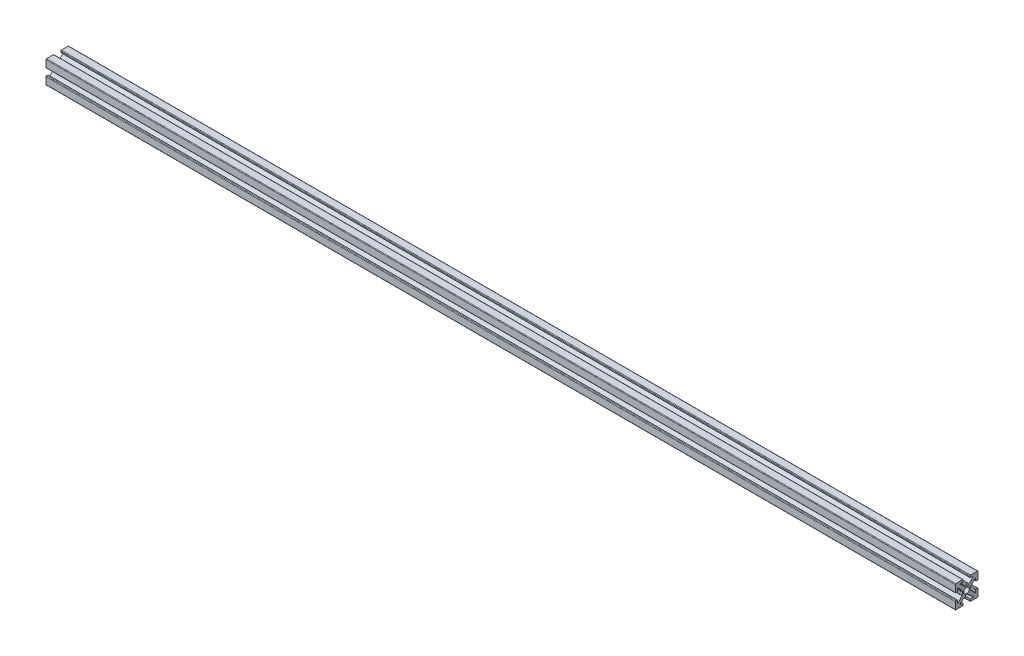
from build123d import *

# Parameters (mm, degrees)
ESTRUSIONE_ESTRUSIONE1_DEPTH = 400
FORO_FILETTATO_M3X0_5_1_D    = 2.5


with BuildPart() as part:
    # Sketch1 → Estrusione-Estrusione1 (new body)
    with BuildSketch(Plane(origin=(0, 0, 0), x_dir=(0, 0, -1), z_dir=(1, 0, 0))):
        with BuildLine():
            Line((-0.2413, 1.4986), (0.2413, 1.4986))
            ThreePointArc((0.2413, 1.4986), (0.420905122, 1.572994878), (0.4953, 1.7526))
            ThreePointArc((0.4953, 1.7526), (0.569694878, 1.932205122), (0.7493, 2.0066))
            Line((0.7493, 2.0066), (0.889923986, 2.0066))
            ThreePointArc((0.889923986, 2.0066), (0.983516259, 2.024471886), (1.063937899, 2.075572548))
            Line((1.063937899, 2.075572548), (2.890793, 3.793686274))
            ThreePointArc((2.890793, 3.793686274), (2.921850101, 3.932996137), (2.803786044, 4.0132))
            Line((2.803786044, 4.0132), (1.7526, 4.0132))
            ThreePointArc((1.7526, 4.0132), (1.572994878, 4.087594878), (1.4986, 4.2672))
            Line((1.4986, 4.2672), (1.4986, 4.7498))
            ThreePointArc((1.4986, 4.7498), (1.572994878, 4.929405122), (1.7526, 5.0038))
            Line((1.7526, 5.0038), (4.7498, 5.0038))
            ThreePointArc((4.7498, 5.0038), (4.929405122, 4.929405122), (5.0038, 4.7498))
            Line((5.0038, 4.7498), (5.0038, 1.7526))
            ThreePointArc((5.0038, 1.7526), (4.929405122, 1.572994878), (4.7498, 1.4986))
            Line((4.7498, 1.4986), (4.2672, 1.4986))
            ThreePointArc((4.2672, 1.4986), (4.087594878, 1.572994878), (4.0132, 1.7526))
            Line((4.0132, 1.7526), (4.0132, 2.803786044))
            ThreePointArc((4.0132, 2.803786044), (3.932996137, 2.921850101), (3.793686274, 2.890793))
            Line((3.793686274, 2.890793), (2.075572548, 1.063937899))
            ThreePointArc((2.075572548, 1.063937899), (2.024471886, 0.983516259), (2.0066, 0.889923986))
            Line((2.0066, 0.889923986), (2.0066, 0.7493))
            ThreePointArc((2.0066, 0.7493), (1.932205122, 0.569694878), (1.7526, 0.4953))
            ThreePointArc((1.7526, 0.4953), (1.572994878, 0.420905122), (1.4986, 0.2413))
            Line((1.4986, 0.2413), (1.4986, -0.2413))
            ThreePointArc((1.4986, -0.2413), (1.572994878, -0.420905122), (1.7526, -0.4953))
            ThreePointArc((1.7526, -0.4953), (1.932205122, -0.569694878), (2.0066, -0.7493))
            Line((2.0066, -0.7493), (2.0066, -0.889923986))
            ThreePointArc((2.0066, -0.889923986), (2.024471886, -0.983516259), (2.075572548, -1.063937899))
            Line((2.075572548, -1.063937899), (3.793686274, -2.890793))
            ThreePointArc((3.793686274, -2.890793), (3.932996137, -2.921850101), (4.0132, -2.803786044))
            Line((4.0132, -2.803786044), (4.0132, -1.7526))
            ThreePointArc((4.0132, -1.7526), (4.087594878, -1.572994878), (4.2672, -1.4986))
            Line((4.2672, -1.4986), (4.7498, -1.4986))
            ThreePointArc((4.7498, -1.4986), (4.929405122, -1.572994878), (5.0038, -1.7526))
            Line((5.0038, -1.7526), (5.0038, -4.7498))
            ThreePointArc((5.0038, -4.7498), (4.929405122, -4.929405122), (4.7498, -5.0038))
            Line((4.7498, -5.0038), (1.7526, -5.0038))
            ThreePointArc((1.7526, -5.0038), (1.572994878, -4.929405122), (1.4986, -4.7498))
            Line((1.4986, -4.7498), (1.4986, -4.2672))
            ThreePointArc((1.4986, -4.2672), (1.572994878, -4.087594878), (1.7526, -4.0132))
            Line((1.7526, -4.0132), (2.803786044, -4.0132))
            ThreePointArc((2.803786044, -4.0132), (2.921850101, -3.932996137), (2.890793, -3.793686274))
            Line((2.890793, -3.793686274), (1.063937899, -2.075572548))
            ThreePointArc((1.063937899, -2.075572548), (0.983516259, -2.024471886), (0.889923986, -2.0066))
            Line((0.889923986, -2.0066), (0.7493, -2.0066))
            ThreePointArc((0.7493, -2.0066), (0.569694878, -1.932205122), (0.4953, -1.7526))
            ThreePointArc((0.4953, -1.7526), (0.420905122, -1.572994878), (0.2413, -1.4986))
            Line((0.2413, -1.4986), (-0.2413, -1.4986))
            ThreePointArc((-0.2413, -1.4986), (-0.420905122, -1.572994878), (-0.4953, -1.7526))
            ThreePointArc((-0.4953, -1.7526), (-0.569694878, -1.932205122), (-0.7493, -2.0066))
            Line((-0.7493, -2.0066), (-0.889923986, -2.0066))
            ThreePointArc((-0.889923986, -2.0066), (-0.983516259, -2.024471886), (-1.063937899, -2.075572548))
            Line((-1.063937899, -2.075572548), (-2.890793, -3.793686274))
            ThreePointArc((-2.890793, -3.793686274), (-2.921850101, -3.932996137), (-2.803786044, -4.0132))
            Line((-2.803786044, -4.0132), (-1.7526, -4.0132))
            ThreePointArc((-1.7526, -4.0132), (-1.572994878, -4.087594878), (-1.4986, -4.2672))
            Line((-1.4986, -4.2672), (-1.4986, -4.7498))
            ThreePointArc((-1.4986, -4.7498), (-1.572994878, -4.929405122), (-1.7526, -5.0038))
            Line((-1.7526, -5.0038), (-4.7498, -5.0038))
            ThreePointArc((-4.7498, -5.0038), (-4.929405122, -4.929405122), (-5.0038, -4.7498))
            Line((-5.0038, -4.7498), (-5.0038, -1.7526))
            ThreePointArc((-5.0038, -1.7526), (-4.929405122, -1.572994878), (-4.7498, -1.4986))
            Line((-4.7498, -1.4986), (-4.2672, -1.4986))
            ThreePointArc((-4.2672, -1.4986), (-4.087594878, -1.572994878), (-4.0132, -1.7526))
            Line((-4.0132, -1.7526), (-4.0132, -2.803786044))
            ThreePointArc((-4.0132, -2.803786044), (-3.932996137, -2.921850101), (-3.793686274, -2.890793))
            Line((-3.793686274, -2.890793), (-2.075572548, -1.063937899))
            ThreePointArc((-2.075572548, -1.063937899), (-2.024471886, -0.983516259), (-2.0066, -0.889923986))
            Line((-2.0066, -0.889923986), (-2.0066, -0.7493))
            ThreePointArc((-2.0066, -0.7493), (-1.932205122, -0.569694878), (-1.7526, -0.4953))
            ThreePointArc((-1.7526, -0.4953), (-1.572994878, -0.420905122), (-1.4986, -0.2413))
            Line((-1.4986, -0.2413), (-1.4986, 0.2413))
            ThreePointArc((-1.4986, 0.2413), (-1.572994878, 0.420905122), (-1.7526, 0.4953))
            ThreePointArc((-1.7526, 0.4953), (-1.932205122, 0.569694878), (-2.0066, 0.7493))
            Line((-2.0066, 0.7493), (-2.0066, 0.889923986))
            ThreePointArc((-2.0066, 0.889923986), (-2.024471886, 0.983516259), (-2.075572548, 1.063937899))
            Line((-2.075572548, 1.063937899), (-3.793686274, 2.890793))
            ThreePointArc((-3.793686274, 2.890793), (-3.932996137, 2.921850101), (-4.0132, 2.803786044))
            Line((-4.0132, 2.803786044), (-4.0132, 1.7526))
            ThreePointArc((-4.0132, 1.7526), (-4.087594878, 1.572994878), (-4.2672, 1.4986))
            Line((-4.2672, 1.4986), (-4.7498, 1.4986))
            ThreePointArc((-4.7498, 1.4986), (-4.929405122, 1.572994878), (-5.0038, 1.7526))
            Line((-5.0038, 1.7526), (-5.0038, 4.7498))
            ThreePointArc((-5.0038, 4.7498), (-4.929405122, 4.929405122), (-4.7498, 5.0038))
            Line((-4.7498, 5.0038), (-1.7526, 5.0038))
            ThreePointArc((-1.7526, 5.0038), (-1.572994878, 4.929405122), (-1.4986, 4.7498))
            Line((-1.4986, 4.7498), (-1.4986, 4.2672))
            ThreePointArc((-1.4986, 4.2672), (-1.572994878, 4.087594878), (-1.7526, 4.0132))
            Line((-1.7526, 4.0132), (-2.803786044, 4.0132))
            ThreePointArc((-2.803786044, 4.0132), (-2.921850101, 3.932996137), (-2.890793, 3.793686274))
            Line((-2.890793, 3.793686274), (-1.063937899, 2.075572548))
            ThreePointArc((-1.063937899, 2.075572548), (-0.983516259, 2.024471886), (-0.889923986, 2.0066))
            Line((-0.889923986, 2.0066), (-0.7493, 2.0066))
            ThreePointArc((-0.7493, 2.0066), (-0.569694878, 1.932205122), (-0.4953, 1.7526))
            ThreePointArc((-0.4953, 1.7526), (-0.420905122, 1.572994878), (-0.2413, 1.4986))
        make_face()
    extrude(amount=ESTRUSIONE_ESTRUSIONE1_DEPTH)

    # Foro filettato M3x0.5-1 (through all)
    with Locations(Plane.ZY):
        with Locations((0, 0)):
            Hole(FORO_FILETTATO_M3X0_5_1_D / 2)


solid = part.part
